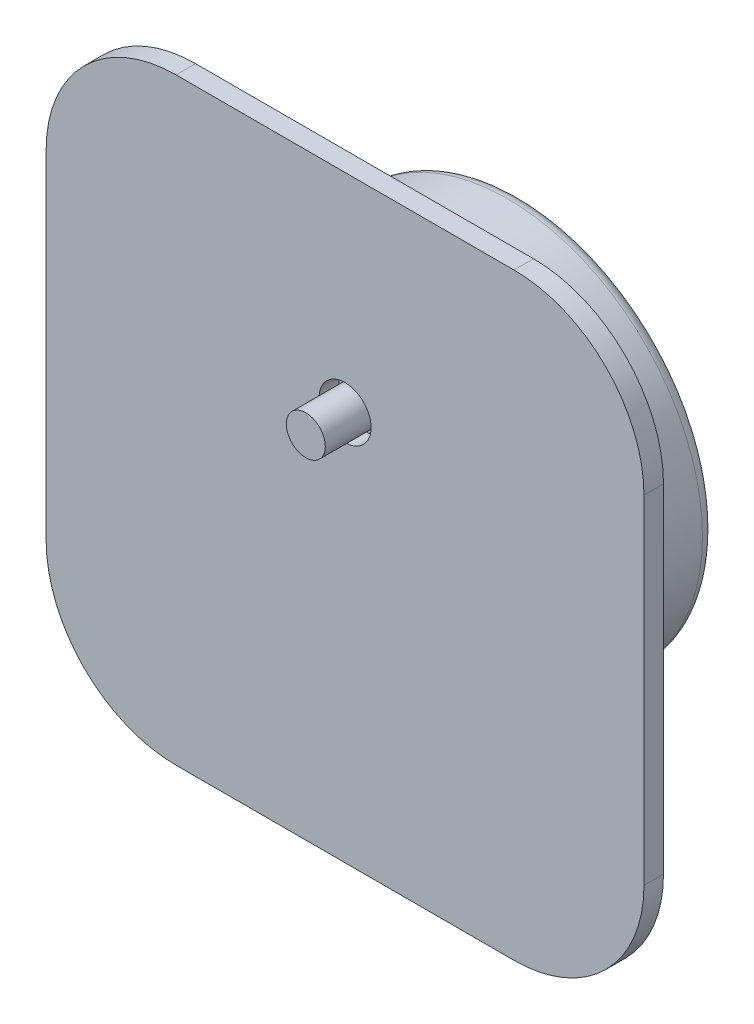
from build123d import *

# Parameters (mm, degrees)
SKETCH1_W           = 46
SKETCH1_H           = 46
SKETCH1_R           = 2
BOSS_EXTRUDE1_DEPTH = 1.5
BOSS_EXTRUDE2_DEPTH = 12
FILLET1_R           = 1
SKETCH4_R           = 1.5
BOSS_EXTRUDE3_DEPTH = 4.52
FILLET2_R           = 10


with BuildPart() as part:
    # Sketch1 → Boss-Extrude1 (new body)
    with BuildSketch(Plane.XY):
        Rectangle(SKETCH1_W, SKETCH1_H)
        with Locations((0, 7)):
            Circle(SKETCH1_R, mode=Mode.SUBTRACT)
    extrude(amount=BOSS_EXTRUDE1_DEPTH)

    # Sketch3 → Boss-Extrude2 (add)
    with BuildSketch(Plane(origin=(0, 0, 0), x_dir=(-1, 0, 0), z_dir=(0, 0, -1))):
        with BuildLine():
            Line((16.045296796, -5.501477845), (13.954703204, -5.501477845))
            ThreePointArc((13.954703204, -5.501477845), (11.306350983, -9.857303254), (7.352141129, -13.074632722))
            ThreePointArc((7.352141129, -13.074632722), (0, -15), (-7.352141129, -13.074632722))
            ThreePointArc((-7.352141129, -13.074632722), (-9.857303254, 11.306350983), (13.954703204, 5.501477845))
            Line((13.954703204, 5.501477845), (16.045296796, 5.501477845))
            Line((16.045296796, 5.501477845), (16.045296796, -5.501477845))
        make_face()
    extrude(amount=BOSS_EXTRUDE2_DEPTH)

    # Fillet1
    fillet1_edges = [part.edges().sort_by_distance(p)[0] for p in [
        (15, 0, -12),
    ]]
    fillet(fillet1_edges, radius=FILLET1_R)

    # Sketch4 → Boss-Extrude3 (add)
    with BuildSketch(Plane.XY):
        with Locations((0, 7)):
            Circle(SKETCH4_R)
    extrude(amount=BOSS_EXTRUDE3_DEPTH)

    # Fillet2
    fillet2_edges = [part.edges().sort_by_distance(p)[0] for p in [
        (23, -23, 0.75),
        (-23, -23, 0.75),
        (-23, 23, 0.75),
        (23, 23, 0.75),
    ]]
    fillet(fillet2_edges, radius=FILLET2_R)


solid = part.part
